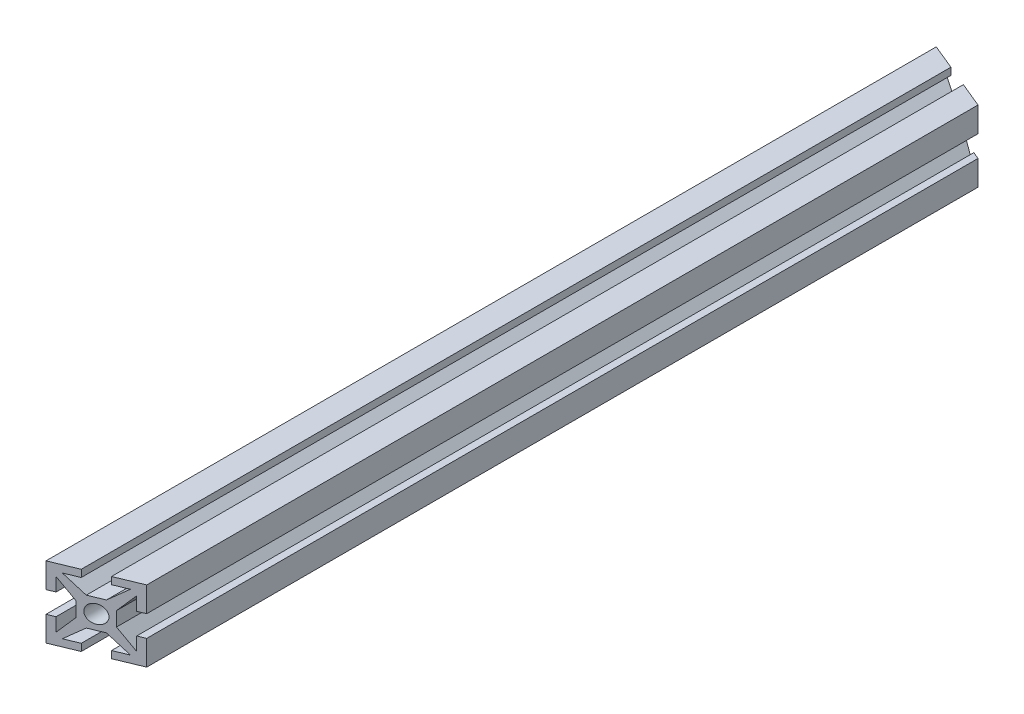
from build123d import *

# Parameters (mm, degrees)
ESQUISSE2_R             = 1.25
BOSS_EXTRU_1_DEPTH      = 125
ENL_V_MAT_EXTRU_1_DEPTH = 11


with BuildPart() as part:
    # Esquisse2 → Boss.-Extru.1 (new body)
    with BuildSketch(Plane.XY):
        Polygon((-1, -2), (1, -2), (3.383507185, -4), (1.5, -4), (1.5, -5), (5, -5), (5, -1.5), (4, -1.5), (4, -3.383507185), (2, -1), (2, 1), (4, 3.383507185), (4, 1.5), (5, 1.5), (5, 5), (1.5, 5), (1.5, 4), (3.383507185, 4), (1, 2), (-1, 2), (-3.383507185, 4), (-1.5, 4), (-1.5, 5), (-5, 5), (-5, 1.5), (-4, 1.5), (-4, 3.383507185), (-2, 1), (-2, -1), (-4, -3.383507185), (-4, -1.5), (-5, -1.5), (-5, -5), (-1.5, -5), (-1.5, -4), (-3.383507185, -4), align=None)
        Circle(ESQUISSE2_R, mode=Mode.SUBTRACT)
    extrude(amount=BOSS_EXTRU_1_DEPTH)

    # Esquisse3 → Enlèv. mat.-Extru.1 (cut, through all)
    with BuildSketch(Plane(origin=(0, 5, 0), x_dir=(1, 0, 0), z_dir=(0, 1, 0))):
        Polygon((-5, 0), (5, 0), (5, -4.142135624), align=None)
        Polygon((5, -120.857864376), (-5, -125), (5, -125), align=None)
    extrude(amount=-ENL_V_MAT_EXTRU_1_DEPTH, mode=Mode.SUBTRACT)


solid = part.part
